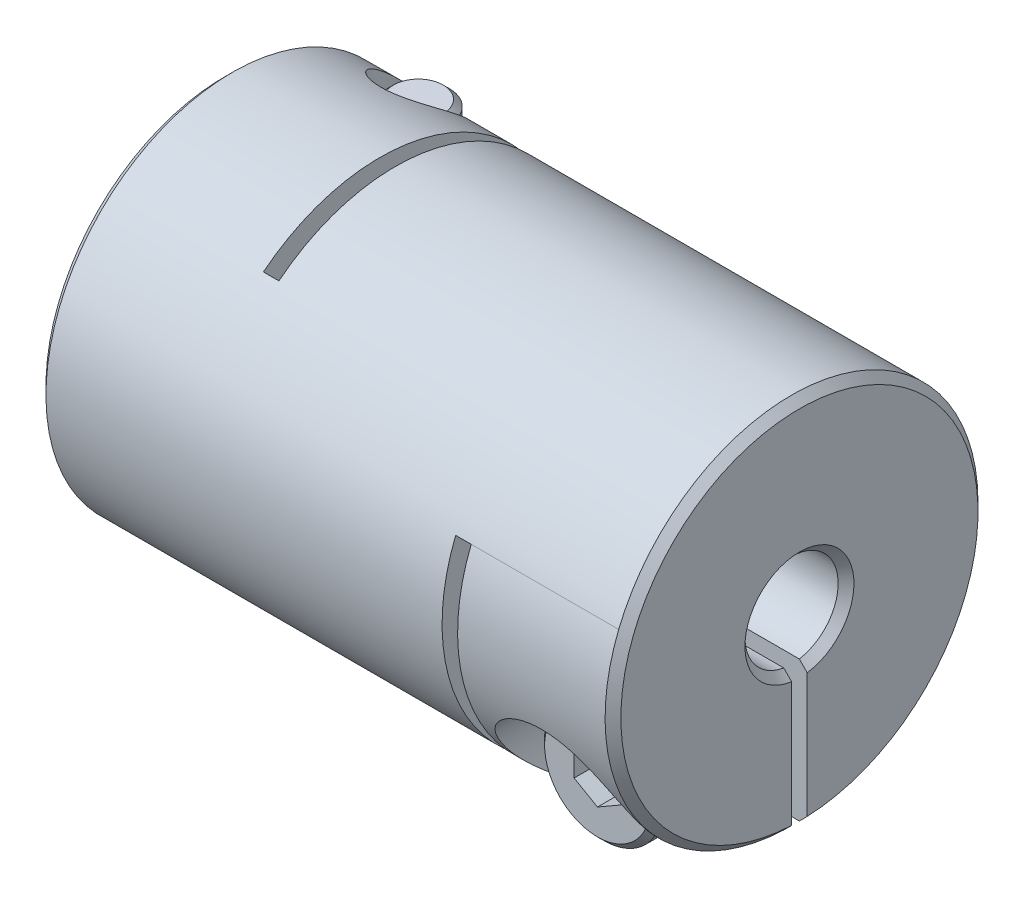
from build123d import *

# Parameters (mm, degrees)
SKETCH1_R                      = 6
BOSS_EXTRUDE1_DEPTH            = 9.25
SKETCH2_R                      = 1.5
CUT_EXTRUDE1_DEPTH             = 19.5
CHAMFER1_SIZE                  = 0.254
SKETCH4_W                      = 0.5
SKETCH4_H                      = 9.75
CUT_EXTRUDE2_DEPTH             = 13
SKETCH7_W                      = 0.5
SKETCH7_H                      = 8.25
CUT_EXTRUDE3_DEPTH             = 13
SKETCH8_W                      = 5
SKETCH8_H                      = 6
CUT_EXTRUDE5_DEPTH             = 0.25
SKETCH13_W                     = 5
SKETCH13_H                     = 6
CUT_EXTRUDE6_DEPTH             = 0.25
CBORE_FOR_M2_SHCS1_D           = 2.4
CBORE_FOR_M2_SHCS1_CBORE_D     = 4.4
CBORE_FOR_M2_SHCS1_CBORE_DEPTH = 4
CBORE_FOR_M2_SHCS2_D           = 2.4
CBORE_FOR_M2_SHCS2_CBORE_D     = 4.4
CBORE_FOR_M2_SHCS2_CBORE_DEPTH = 4
SKETCH16_R                     = 1.9
BOSS_EXTRUDE2_DEPTH            = 2
SKETCH17_R                     = 1
BOSS_EXTRUDE3_DEPTH            = 6.5
CHAMFER2_SIZE                  = 0.2
CUT_EXTRUDE7_DEPTH             = 1.5
CIRPATTERN1_COUNT              = 2
CIRPATTERN1_ANGLE              = 90


with BuildPart() as part:
    # Sketch1 → Boss-Extrude1 (new body, symmetric)
    with BuildSketch(Plane(origin=(0, 0, 0), x_dir=(0, 0, -1), z_dir=(1, 0, 0))):
        Circle(SKETCH1_R)
    extrude(amount=BOSS_EXTRUDE1_DEPTH, both=True)

    # Sketch2 → Cut-Extrude1 (cut, through all)
    with BuildSketch(Plane(origin=(9.25, 0, 0), x_dir=(0, 0, -1), z_dir=(1, 0, 0))):
        Circle(SKETCH2_R)
    extrude(amount=-CUT_EXTRUDE1_DEPTH, mode=Mode.SUBTRACT)

    # Chamfer1
    chamfer1_edges = [part.edges().sort_by_distance(p)[0] for p in [
        (-9.25, 0, 6),
        (9.25, 0, 6),
        (-9.25, 0, 1.5),
        (9.25, 0, 1.5),
    ]]
    chamfer(chamfer1_edges, length=CHAMFER1_SIZE)

    # Sketch4 → Cut-Extrude2 (cut, through all)
    with BuildSketch(Plane.XZ.offset(6)):
        with Locations((-4, -1.125)):
            Rectangle(SKETCH4_W, SKETCH4_H)
    extrude(amount=-CUT_EXTRUDE2_DEPTH, mode=Mode.SUBTRACT)

    # Sketch7 → Cut-Extrude3 (cut, through all)
    with BuildSketch(Plane(origin=(0, 0, -6), x_dir=(-1, 0, 0), z_dir=(0, 0, -1))):
        with Locations((-4, -1.875)):
            Rectangle(SKETCH7_W, SKETCH7_H)
    extrude(amount=-CUT_EXTRUDE3_DEPTH, mode=Mode.SUBTRACT)

    # Sketch8 → Cut-Extrude5 (cut, symmetric)
    with BuildSketch(Plane(origin=(0, 0, 0), x_dir=(1, 0, 0), z_dir=(0, 1, 0))):
        with Locations((-6.75, 3)):
            Rectangle(SKETCH8_W, SKETCH8_H)
    extrude(amount=CUT_EXTRUDE5_DEPTH, both=True, mode=Mode.SUBTRACT)

    # Sketch13 → Cut-Extrude6 (cut, symmetric)
    with BuildSketch(Plane.XY):
        with Locations((6.75, -3)):
            Rectangle(SKETCH13_W, SKETCH13_H)
    extrude(amount=CUT_EXTRUDE6_DEPTH, both=True, mode=Mode.SUBTRACT)

    # CBORE for M2 SHCS1 (through all)
    with Locations(Plane.XZ.offset(6)):
        with Locations((-6.75, -3.736904675)):
            CounterBoreHole(CBORE_FOR_M2_SHCS1_D / 2, CBORE_FOR_M2_SHCS1_CBORE_D / 2, CBORE_FOR_M2_SHCS1_CBORE_DEPTH)

    # CBORE for M2 SHCS2 (through all)
    with Locations(Plane.XY.offset(6)):
        with Locations((6.75, -3.736904675)):
            CounterBoreHole(CBORE_FOR_M2_SHCS2_D / 2, CBORE_FOR_M2_SHCS2_CBORE_D / 2, CBORE_FOR_M2_SHCS2_CBORE_DEPTH)


with BuildPart() as body_2:
    # Sketch16 → Boss-Extrude2 (new body)
    with BuildSketch(Plane.XY.offset(2)):
        with Locations((6.75, -3.736904675)):
            Circle(SKETCH16_R)
    extrude(amount=BOSS_EXTRUDE2_DEPTH)

    # Sketch17 → Boss-Extrude3 (add)
    with BuildSketch(Plane(origin=(0, 0, 2), x_dir=(-1, 0, 0), z_dir=(0, 0, -1))):
        with Locations(Location((-6.75, -3.736904675, 0), (0, 0, 180))):  # turned: the seam where the file's is
            Circle(SKETCH17_R)
    extrude(amount=BOSS_EXTRUDE3_DEPTH)

    # Chamfer2
    chamfer2_edges = [body_2.edges().sort_by_distance(p)[0] for p in [
        (4.85, -3.736904675, 2),
        (4.85, -3.736904675, 4),
        (5.75, -3.736904675, -4.5),
    ]]
    chamfer(chamfer2_edges, length=CHAMFER2_SIZE)

    # Sketch18 → Cut-Extrude7 (cut)
    with BuildSketch(Plane.XY.offset(4)):
        Polygon((6.75, -4.602930079), (7.5, -4.169917377), (7.5, -3.303891973), (6.75, -2.870879271), (6, -3.303891973), (6, -4.169917377), align=None)
    extrude(amount=-CUT_EXTRUDE7_DEPTH, mode=Mode.SUBTRACT)


with BuildPart() as body_3:
    # Mirror1: mirrored copy
    add(body_2.part.mirror(Plane(origin=(0, 0, 0), x_dir=(0, 0, 1), z_dir=(1, 0, 0))))


with BuildPart() as cirpattern1_1:
    # CirPattern1: pattern copy
    add(body_3.part.rotate(Axis((0, 0, 0), (1, 0, 0)), 1 * CIRPATTERN1_ANGLE / (CIRPATTERN1_COUNT - 1)))


solid = Compound([part.part, body_2.part, cirpattern1_1.part])
